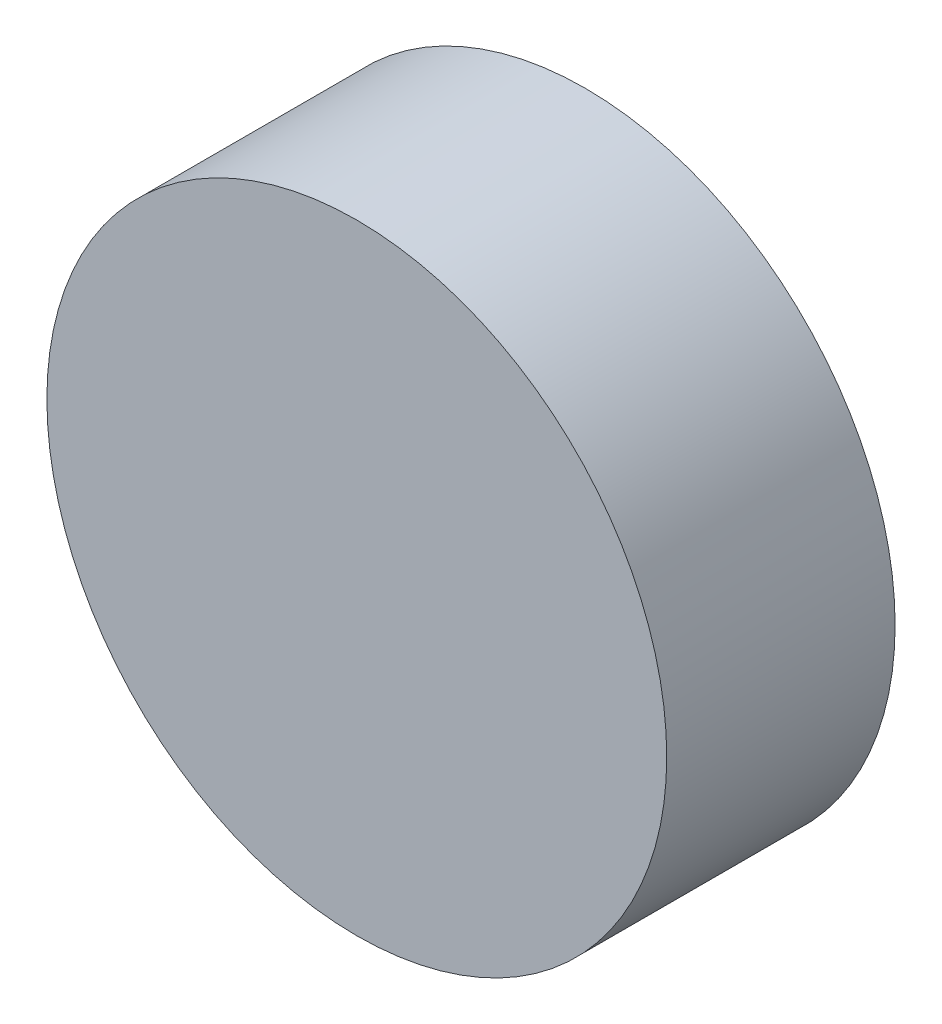
from build123d import *

# Parameters (mm, degrees)
SKETCH1_R           = 19
BOSS_EXTRUDE1_DEPTH = 14


with BuildPart() as part:
    # Sketch1 → Boss-Extrude1 (new body)
    with BuildSketch(Plane.XY):
        Circle(SKETCH1_R)
    extrude(amount=BOSS_EXTRUDE1_DEPTH)


solid = part.part
